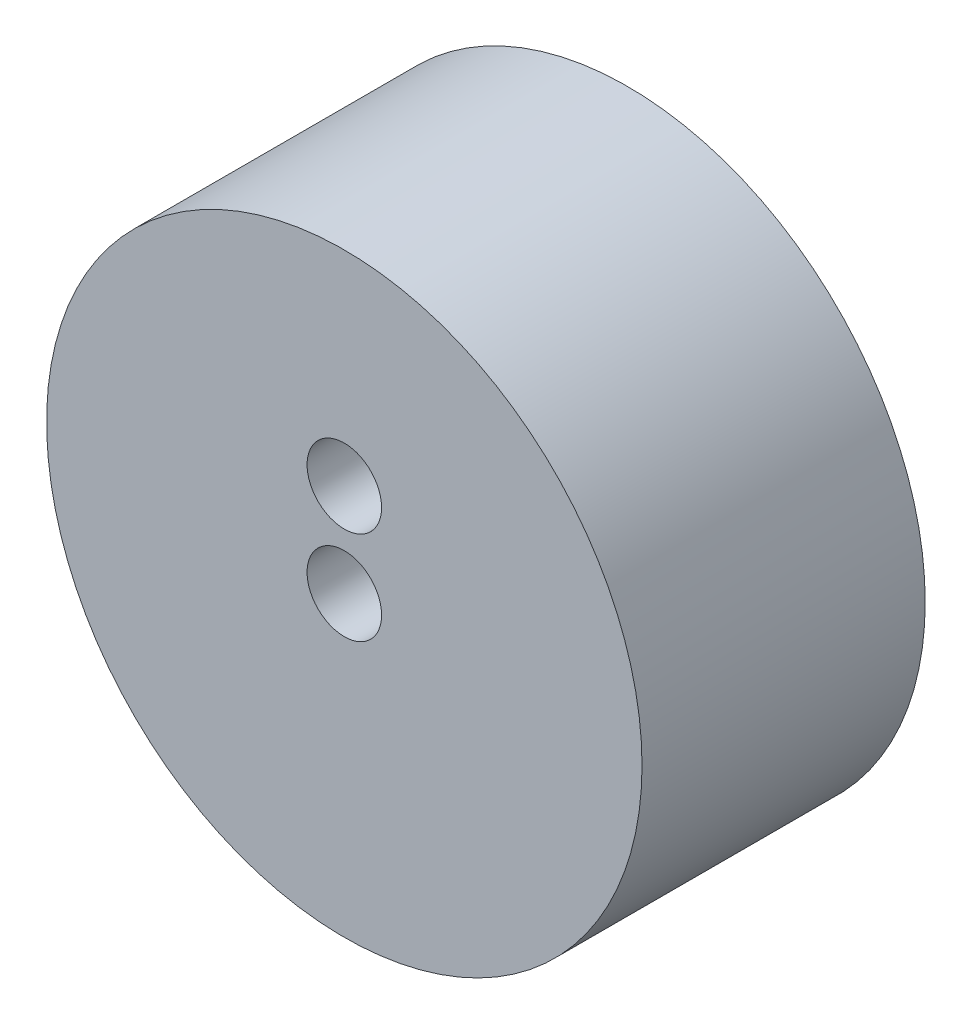
from build123d import *

# Parameters (mm, degrees)
SKETCH1_R      = 15.98
EXTRUDE1_DEPTH = 15.2
SKETCH8_R      = 2
EXTRUDE3_DEPTH = 16.2
SKETCH9_R      = 2
EXTRUDE4_DEPTH = 16.2


with BuildPart() as part:
    # Sketch1 → Extrude1 (new body)
    with BuildSketch(Plane.XY):
        Circle(SKETCH1_R)
    extrude(amount=EXTRUDE1_DEPTH)

    # Sketch8 → Extrude3 (cut, through all)
    with BuildSketch(Plane.XY.offset(15.2)):
        Circle(SKETCH8_R)
    extrude(amount=-EXTRUDE3_DEPTH, mode=Mode.SUBTRACT)

    # Sketch9 → Extrude4 (cut, through all)
    with BuildSketch(Plane.XY.offset(15.2)):
        with Locations((0, 5)):
            Circle(SKETCH9_R)
    extrude(amount=-EXTRUDE4_DEPTH, mode=Mode.SUBTRACT)


solid = part.part
